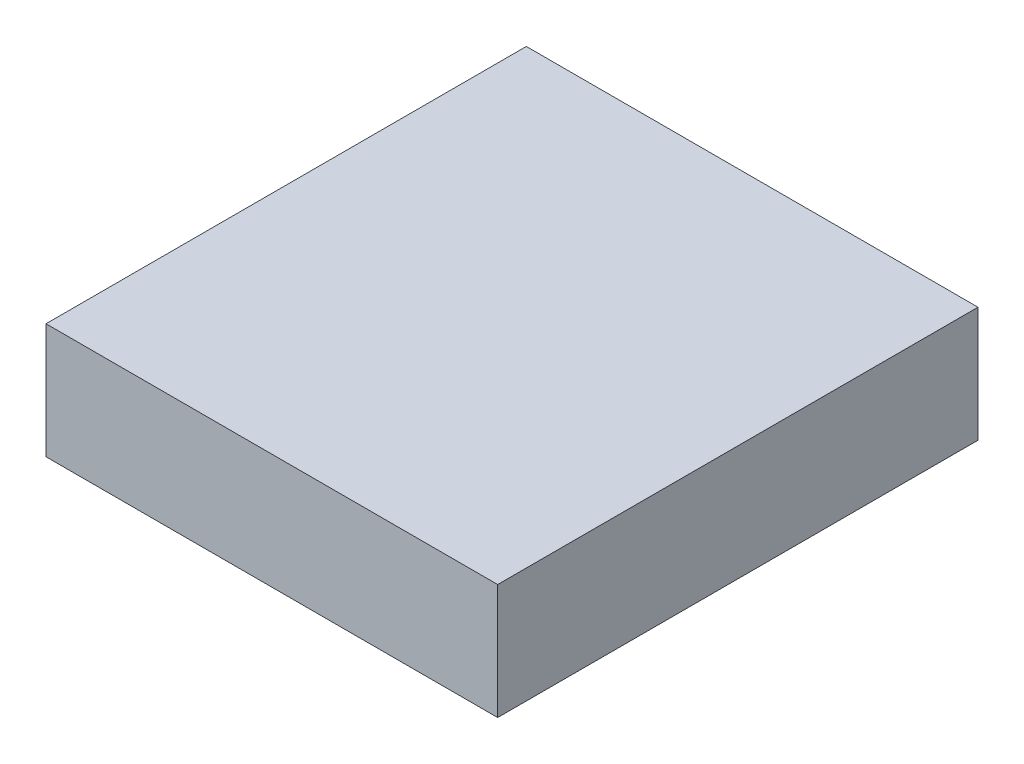
from build123d import *

# Parameters (mm, degrees)
SKETCH1_W           = 90.17
SKETCH1_H           = 95.89
BOSS_EXTRUDE1_DEPTH = 11.5


with BuildPart() as part:
    # Sketch1 → Boss-Extrude1 (new body, symmetric)
    with BuildSketch(Plane(origin=(0, 0, 0), x_dir=(1, 0, 0), z_dir=(0, 1, 0))):
        with Locations((0, -0.05)):
            Rectangle(SKETCH1_W, SKETCH1_H)
    extrude(amount=BOSS_EXTRUDE1_DEPTH, both=True)


solid = part.part
